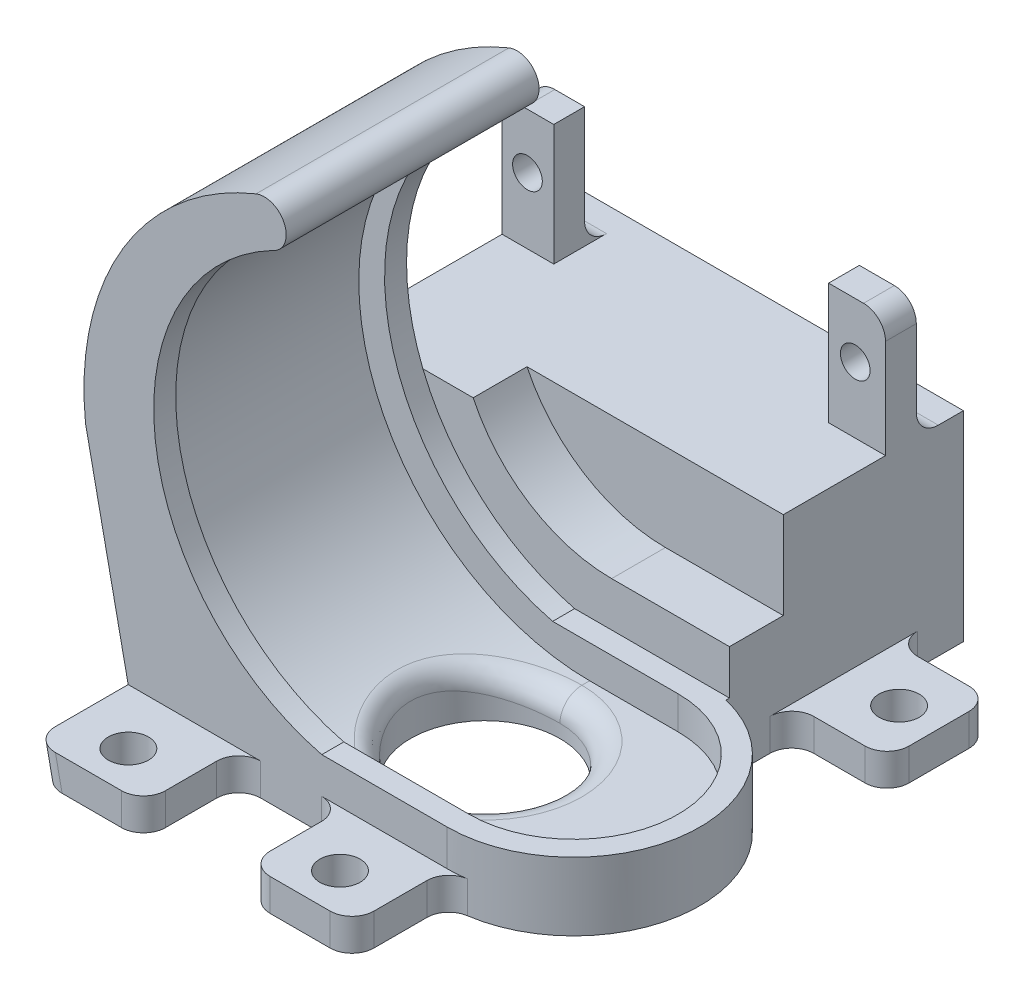
from build123d import *

# Parameters (mm, degrees)
SKETCH1_W                       = 63.5
SKETCH1_H                       = 24.13
BOSS_EXTRUDE1_DEPTH             = 4.064
BOSS_EXTRUDE2_REACH             = 14.065
BOSS_EXTRUDE2_DIRECTION_2_REACH = 14.065
SKETCH4_R                       = 8.636
CUT_EXTRUDE1_DEPTH              = 4.064
CUT_EXTRUDE1_DEPTH_BACK         = 5.064
FILLET1_R                       = 2.54
CUT_EXTRUDE2_DEPTH              = 25.1300001
BOSS_EXTRUDE3_DEPTH             = 2.54
BOSS_EXTRUDE4_DEPTH             = 2.54
BOSS_EXTRUDE5_DEPTH             = 3.81
CUT_EXTRUDE3_DEPTH              = 8.8740001
BOSS_EXTRUDE6_START             = -23.114
SKETCH12_W                      = 44.831
SKETCH12_H                      = 27.027043781
BOSS_EXTRUDE6_DEPTH             = 23.114
BOSS_EXTRUDE7_DEPTH             = 7.874
CUT_EXTRUDE4_START              = -6.219751
CUT_EXTRUDE4_DEPTH              = 6.219751
CUT_EXTRUDE5_DEPTH              = 27.027044
SKETCH17_W                      = 6.9977
SKETCH17_H                      = 3.556
BOSS_EXTRUDE8_DEPTH             = 13.97
SKETCH18_W                      = 6.389869694
SKETCH18_H                      = 3.556
BOSS_EXTRUDE9_DEPTH             = 13.97
SKETCH19_W                      = 31.75
SKETCH19_H                      = 7.112
CUT_EXTRUDE6_DEPTH              = 13.97
CUT_EXTRUDE7_REACH              = 52.797
SKETCH20_R                      = 1.7145
FILLET2_R                       = 2.54
FILLET3_R                       = 2.54
FILLET4_R                       = 2.54
SKETCH21_W                      = 12
SKETCH21_H                      = 11
SKETCH21_W_2                    = 11
SKETCH21_H_2                    = 12
BOSS_EXTRUDE10_DEPTH            = 3.7
BOSS_EXTRUDE11_DEPTH            = 11
FILLET5_R                       = 2.54
SKETCH23_R                      = 2.325
CUT_EXTRUDE8_DEPTH              = 4.7000001


with BuildPart() as part:
    # Sketch1 → Boss-Extrude1 (new body)
    with BuildSketch(Plane(origin=(0, 0, 0), x_dir=(1, 0, 0), z_dir=(0, 1, 0))):
        Rectangle(SKETCH1_W, SKETCH1_H)
    extrude(amount=BOSS_EXTRUDE1_DEPTH)

    # Boss-Extrude2: up to this face of the body (flat: up to its plane)
    boss_extrude2_end = Plane(part.part.faces().sort_by_distance((0, 2.032, 12.065))[0])
    # Sketch2 → Boss-Extrude2 (add, up to the picked face)
    with BuildSketch(Plane.XY, mode=Mode.PRIVATE) as boss_extrude2_sk1:
        with BuildLine():
            Line((0, 4.064), (-26.716755185, 4.064))
            Line((-26.716755185, 4.064), (-31.571041118, 27.367716778))
            ThreePointArc((-31.571041118, 27.367716778), (-27.221246487, 47.076161415), (-11.87173913, 60.180974548))
            ThreePointArc((-11.87173913, 60.180974548), (-8.566242036, 58.774955714), (-9.97226087, 55.46945862))
            ThreePointArc((-9.97226087, 55.46945862), (-26.181898149, 25.654914521), (0, 4.064))
        make_face()
    boss_extrude2_tool1 = split(extrude(boss_extrude2_sk1.sketch, amount=BOSS_EXTRUDE2_REACH, mode=Mode.PRIVATE), bisect_by=boss_extrude2_end, keep=Keep.BOTH, mode=Mode.PRIVATE)
    add(boss_extrude2_tool1.solids().sort_by_distance((-9.165723, 58.533271, 0))[0])

    # Boss-Extrude2 direction 2: up to this face of the body (flat: up to its plane)
    boss_extrude2_direction_2_end = Plane(part.part.faces().sort_by_distance((0, 2.032, -12.065))[0])
    # Sketch2 → Boss-Extrude2 direction 2 (add, up to the picked face)
    with BuildSketch(Plane.XY, mode=Mode.PRIVATE) as boss_extrude2_direction_2_sk1:
        with BuildLine():
            Line((0, 4.064), (-26.716755185, 4.064))
            Line((-26.716755185, 4.064), (-31.571041118, 27.367716778))
            ThreePointArc((-31.571041118, 27.367716778), (-27.221246487, 47.076161415), (-11.87173913, 60.180974548))
            ThreePointArc((-11.87173913, 60.180974548), (-8.566242036, 58.774955714), (-9.97226087, 55.46945862))
            ThreePointArc((-9.97226087, 55.46945862), (-26.181898149, 25.654914521), (0, 4.064))
        make_face()
    boss_extrude2_direction_2_tool1 = split(extrude(boss_extrude2_direction_2_sk1.sketch, amount=-BOSS_EXTRUDE2_DIRECTION_2_REACH, mode=Mode.PRIVATE), bisect_by=boss_extrude2_direction_2_end, keep=Keep.BOTH, mode=Mode.PRIVATE)
    add(boss_extrude2_direction_2_tool1.solids().sort_by_distance((-9.165723, 58.533271, 0))[0])

    # Sketch4 → Cut-Extrude1 (cut, two sides)
    with BuildSketch(Plane(origin=(0, 4.064, 0), x_dir=(1, 0, 0), z_dir=(0, 1, 0))) as cut_extrude1_sk:
        Circle(SKETCH4_R)
    extrude(amount=CUT_EXTRUDE1_DEPTH, mode=Mode.SUBTRACT)
    extrude(cut_extrude1_sk.sketch, amount=-CUT_EXTRUDE1_DEPTH_BACK, mode=Mode.SUBTRACT)

    # Fillet1
    fillet1_edges = [part.edges().sort_by_distance(p)[0] for p in [
        (-8.636, 5.50091846, 0),
        (6.106574162, 4.064, 6.106574162),
    ]]
    fillet(fillet1_edges, radius=FILLET1_R)

    # Sketch6 → Cut-Extrude2 (cut, through all)
    with BuildSketch(Plane.XY.offset(12.065)):
        Polygon((-31.75, 4.064), (-26.716755185, 4.064), (-25.870202757, 0), (-31.75, 0), align=None)
    extrude(amount=-CUT_EXTRUDE2_DEPTH, mode=Mode.SUBTRACT)

    # Sketch8 → Boss-Extrude3 (add)
    with BuildSketch(Plane.XY.offset(12.065)):
        with BuildLine():
            Line((31.75, 0), (31.75, 7.874))
            Line((31.75, 7.874), (-4.274632474, 7.874))
            ThreePointArc((-4.274632474, 7.874), (-23.508790492, 29.710248048), (-9.97226087, 55.46945862))
            ThreePointArc((-9.97226087, 55.46945862), (-8.566242036, 58.774955714), (-11.87173913, 60.180974548))
            ThreePointArc((-11.87173913, 60.180974548), (-27.221246487, 47.076161415), (-31.571041118, 27.367716778))
            Line((-31.571041118, 27.367716778), (-25.870202757, 0))
            Line((-25.870202757, 0), (31.75, 0))
        make_face()
    extrude(amount=BOSS_EXTRUDE3_DEPTH)

    # Sketch9 → Boss-Extrude4 (add)
    with BuildSketch(Plane(origin=(0, 0, -12.065), x_dir=(-1, 0, 0), z_dir=(0, 0, -1))):
        with BuildLine():
            Line((-31.75, 0), (-31.75, 7.874))
            Line((-31.75, 7.874), (4.274632474, 7.874))
            ThreePointArc((4.274632474, 7.874), (23.508790492, 29.710248048), (9.97226087, 55.46945862))
            ThreePointArc((9.97226087, 55.46945862), (8.566242036, 58.774955714), (11.87173913, 60.180974548))
            ThreePointArc((11.87173913, 60.180974548), (27.221246487, 47.076161415), (31.571041118, 27.367716778))
            Line((31.571041118, 27.367716778), (25.870202757, 0))
            Line((25.870202757, 0), (-31.75, 0))
        make_face()
    extrude(amount=BOSS_EXTRUDE4_DEPTH)

    # Sketch10 → Boss-Extrude5 (add)
    with BuildSketch(Plane(origin=(0, 4.064, 0), x_dir=(1, 0, 0), z_dir=(0, 1, 0))):
        with BuildLine():
            Line((10.218295125, 14.605), (10.218295125, 12.065))
            ThreePointArc((10.218295125, 12.065), (22.283295125, 0), (10.218295125, -12.065))
            Line((10.218295125, -12.065), (10.218295125, -14.605))
            ThreePointArc((10.218295125, -14.605), (24.823295125, 0), (10.218295125, 14.605))
        make_face()
    extrude(amount=BOSS_EXTRUDE5_DEPTH)

    # Sketch11 → Cut-Extrude3 (cut, through all)
    with BuildSketch(Plane(origin=(0, 7.874, 0), x_dir=(1, 0, 0), z_dir=(0, 1, 0))):
        with BuildLine():
            Line((10.218295125, 14.605), (31.75, 14.605))
            Line((31.75, 14.605), (31.75, -14.605))
            Line((31.75, -14.605), (10.218295125, -14.605))
            ThreePointArc((10.218295125, -14.605), (24.823295125, 0), (10.218295125, 14.605))
        make_face()
    extrude(amount=-CUT_EXTRUDE3_DEPTH, mode=Mode.SUBTRACT)

    # Sketch12 → Boss-Extrude6 (add)
    with BuildSketch(Plane.XZ.offset(BOSS_EXTRUDE6_START)):
        with Locations((-8.8011, -28.11852189)):
            Rectangle(SKETCH12_W, SKETCH12_H)
    extrude(amount=BOSS_EXTRUDE6_DEPTH)

    # Sketch13 → Boss-Extrude7 (add)
    with BuildSketch(Plane.XZ):
        Polygon((10.218295125, -14.605), (13.6144, -14.605), (13.6144, -13.335525526), align=None)
    extrude(amount=-BOSS_EXTRUDE7_DEPTH)

    # Sketch14 → Cut-Extrude4 (cut)
    with BuildSketch(Plane.XY.offset(-14.605).offset(CUT_EXTRUDE4_START)):
        with BuildLine():
            Line((0, 13.017313502), (18.620278687, 13.017313502))
            Line((18.620278687, 13.017313502), (17.716686498, 30.734))
            ThreePointArc((17.716686498, 30.734), (-12.527589163, 43.261589163), (0, 13.017313502))
        make_face()
    extrude(amount=CUT_EXTRUDE4_DEPTH, mode=Mode.SUBTRACT)

    # Sketch16 → Cut-Extrude5 (cut)
    with BuildSketch(Plane.XY.offset(-14.605)):
        Polygon((-31.2166, 23.114), (-30.684969694, 23.114), (-25.870202757, 0), (-31.2166, 0), align=None)
    extrude(amount=-CUT_EXTRUDE5_DEPTH, mode=Mode.SUBTRACT)

    # Sketch17 → Boss-Extrude8 (add)
    with BuildSketch(Plane(origin=(0, 23.114, 0), x_dir=(1, 0, 0), z_dir=(0, 1, 0))):
        with Locations((10.11555, 34.413750632)):
            Rectangle(SKETCH17_W, SKETCH17_H)
    extrude(amount=BOSS_EXTRUDE8_DEPTH)

    # Sketch18 → Boss-Extrude9 (add)
    with BuildSketch(Plane(origin=(0, 23.114, 0), x_dir=(1, 0, 0), z_dir=(0, 1, 0))):
        with Locations((-27.490034847, 34.413750632)):
            Rectangle(SKETCH18_W, SKETCH18_H)
    extrude(amount=BOSS_EXTRUDE9_DEPTH)

    # Sketch19 → Cut-Extrude6 (cut)
    with BuildSketch(Plane(origin=(0, 37.084, 0), x_dir=(1, 0, 0), z_dir=(0, 1, 0))):
        with Locations((-8.8392, 36.191750632)):
            Rectangle(SKETCH19_W, SKETCH19_H)
    extrude(amount=-CUT_EXTRUDE6_DEPTH, mode=Mode.SUBTRACT)

    # Sketch20 → Cut-Extrude7 (cut, up to next)
    with BuildSketch(Plane(origin=(0, 0, -36.191750632), x_dir=(-1, 0, 0), z_dir=(0, 0, -1)), mode=Mode.PRIVATE) as cut_extrude7_sk1:
        with Locations((27.75585, 30.734)):
            Circle(SKETCH20_R)
    cut_extrude7_tool1 = extrude(cut_extrude7_sk1.sketch, amount=-CUT_EXTRUDE7_REACH, mode=Mode.PRIVATE) & part.part
    add(cut_extrude7_tool1.solids().sort_by_distance((-27.75585, 30.734, -36.191751))[0], mode=Mode.SUBTRACT)
    # Sketch20 → Cut-Extrude7 (cut, up to next)
    with BuildSketch(Plane(origin=(0, 0, -36.191750632), x_dir=(-1, 0, 0), z_dir=(0, 0, -1)), mode=Mode.PRIVATE) as cut_extrude7_sk2:
        with Locations((-10.11555, 30.734)):
            Circle(SKETCH20_R)
    cut_extrude7_tool2 = extrude(cut_extrude7_sk2.sketch, amount=-CUT_EXTRUDE7_REACH, mode=Mode.PRIVATE) & part.part
    add(cut_extrude7_tool2.solids().sort_by_distance((10.11555, 30.734, -36.191751))[0], mode=Mode.SUBTRACT)

    # Fillet2
    fillet2_edges = [part.edges().sort_by_distance(p)[0] for p in [
        (10.3251, 23.114, -36.191750632),
    ]]
    fillet(fillet2_edges, radius=FILLET2_R)

    # Fillet3
    fillet3_edges = [part.edges().sort_by_distance(p)[0] for p in [
        (-27.699584847, 23.114, -36.191750632),
    ]]
    fillet(fillet3_edges, radius=FILLET3_R)

    # Fillet4
    fillet4_edges = [part.edges().sort_by_distance(p)[0] for p in [
        (13.6144, 37.084, -34.413750632),
        (-30.684969694, 37.084, -34.413750632),
    ]]
    fillet(fillet4_edges, radius=FILLET4_R)

    # Sketch21 → Boss-Extrude10 (add)
    with BuildSketch(Plane.XZ):
        with Locations((-19.870202757, 20.105)):
            Rectangle(SKETCH21_W, SKETCH21_H)
        with Locations((4.218295125, 20.105)):
            Rectangle(SKETCH21_W, SKETCH21_H)
        with Locations((19.1144, -27.812319928)):
            Rectangle(SKETCH21_W_2, SKETCH21_H_2)
    extrude(amount=-BOSS_EXTRUDE10_DEPTH)

    # Sketch22 → Boss-Extrude11 (add)
    with BuildSketch(Plane.XY.offset(14.605)):
        Polygon((-25.870202757, 3.7), (-26.640932084, 3.7), (-25.870202757, 0), align=None)
    extrude(amount=BOSS_EXTRUDE11_DEPTH)

    # Fillet5
    fillet5_edges = [part.edges().sort_by_distance(p)[0] for p in [
        (10.218295125, 1.85, 14.605),
        (-13.870202757, 1.85, 25.605),
        (-13.870202757, 1.85, 14.605),
        (10.218295125, 1.85, 25.605),
        (-1.781704875, 1.85, 14.605),
        (-1.781704875, 1.85, 25.605),
        (13.6144, 1.85, -33.812319928),
        (13.6144, 1.85, -21.812319928),
        (24.6144, 1.85, -21.812319928),
        (24.6144, 1.85, -33.812319928),
        (-26.25556742, 1.85, 25.605),
    ]]
    fillet(fillet5_edges, radius=FILLET5_R)

    # Sketch23 → Cut-Extrude8 (cut, through all)
    with BuildSketch(Plane(origin=(0, 3.7, 0), x_dir=(1, 0, 0), z_dir=(0, 1, 0))):
        with Locations((20.0034, 27.812319928)):
            Circle(SKETCH23_R)
        with Locations((-20.228306672, -20.994)):
            Circle(SKETCH23_R)
        with Locations((4.218295125, -20.994)):
            Circle(SKETCH23_R)
    extrude(amount=-CUT_EXTRUDE8_DEPTH, mode=Mode.SUBTRACT)


solid = part.part
